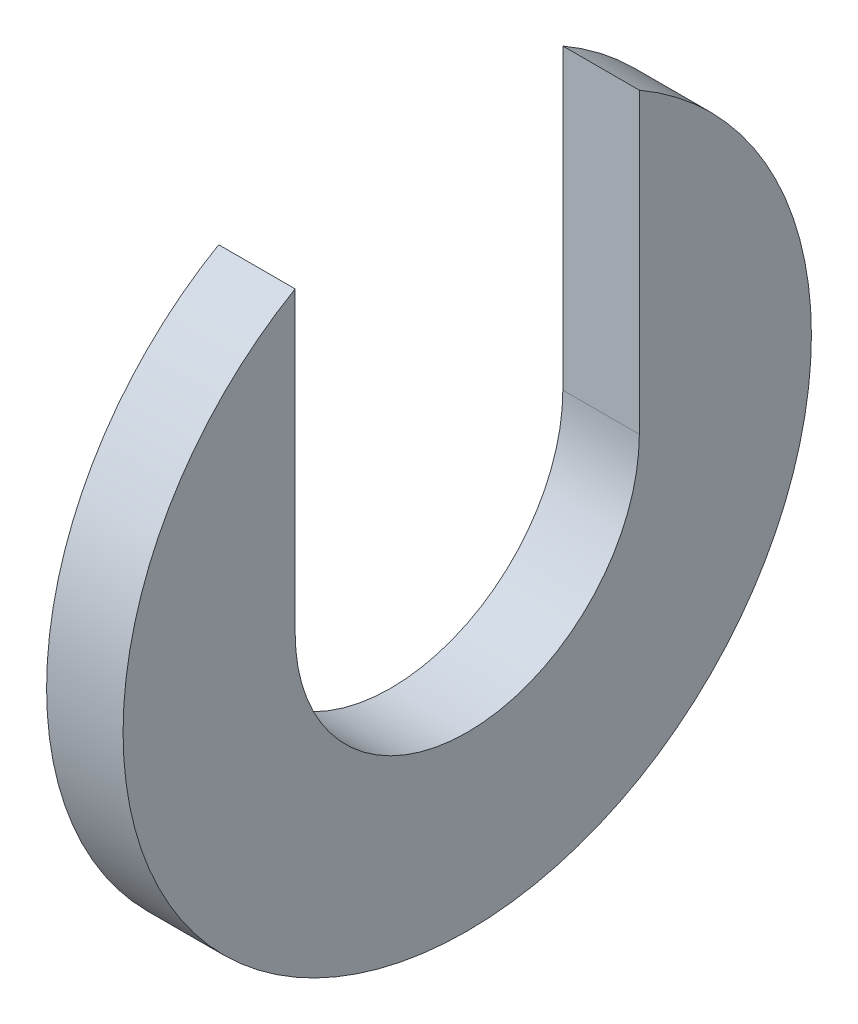
from build123d import *

# Parameters (mm, degrees)
SKETCH1_R               = 9
SKETCH1_R_2             = 4.5
BOSS_EXTRUDE1_DEPTH     = 1
SKETCH3_W               = 2
SKETCH3_H               = 9
CUT_EXTRUDE_THIN1_DEPTH = 10


with BuildPart() as part:
    # Sketch1 → Boss-Extrude1 (new body, symmetric)
    with BuildSketch(Plane(origin=(0, 0, 0), x_dir=(0, 0, -1), z_dir=(1, 0, 0))):
        Circle(SKETCH1_R)
        Circle(SKETCH1_R_2, mode=Mode.SUBTRACT)
    extrude(amount=BOSS_EXTRUDE1_DEPTH, both=True)

    # Sketch3 → Cut-Extrude-Thin1 (cut, through all)
    with BuildSketch(Plane(origin=(0, 0, 0), x_dir=(1, 0, 0), z_dir=(0, 1, 0))):
        Rectangle(SKETCH3_W, SKETCH3_H)
    extrude(amount=CUT_EXTRUDE_THIN1_DEPTH, mode=Mode.SUBTRACT)


solid = part.part
